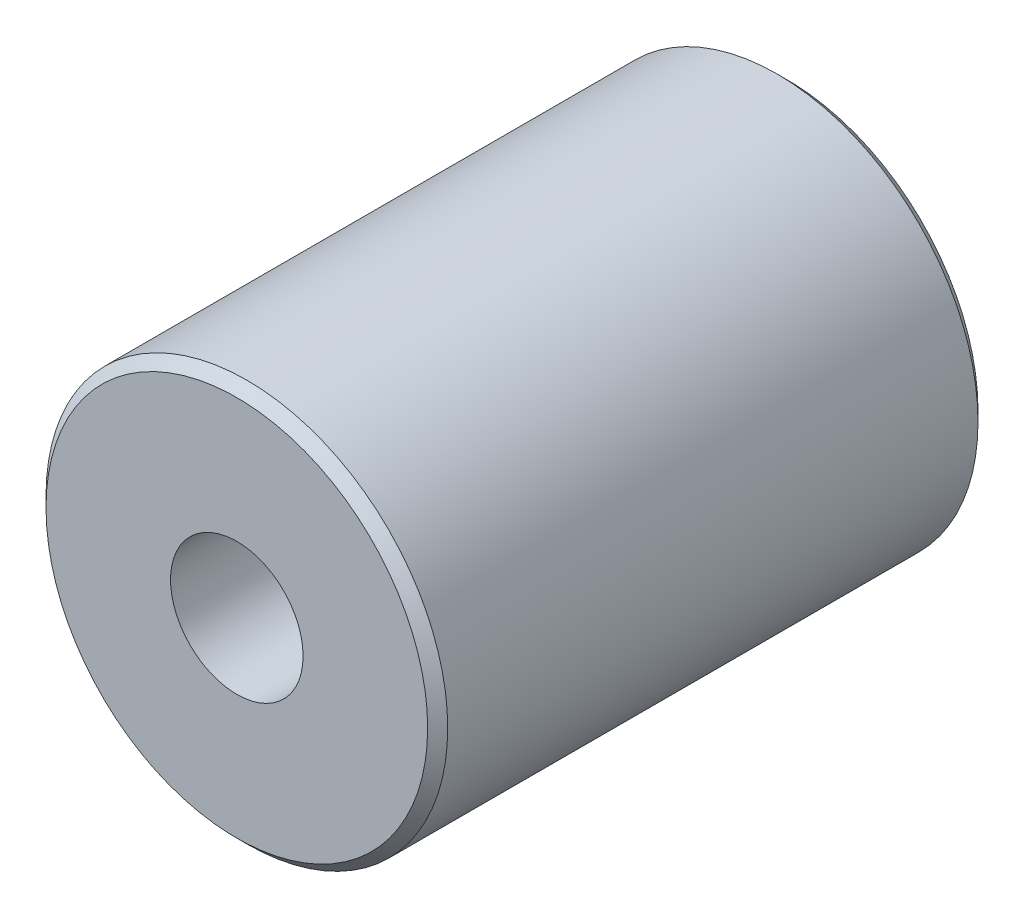
from build123d import *

# Parameters (mm, degrees)
SKETCH1_R                 = 5
EXTRUDE1_DEPTH            = 13.7
M4X0_7_TAPPED_HOLE1_D     = 3.3
M4X0_7_TAPPED_HOLE1_DEPTH = 10
M4X0_7_TAPPED_HOLE1_TIP   = 0.991420021
M4X0_7_TAPPED_HOLE2_D     = 3.3
M4X0_7_TAPPED_HOLE2_DEPTH = 10
M4X0_7_TAPPED_HOLE2_TIP   = 0.991420021
CHAMFER1_SIZE             = 0.25


with BuildPart() as part:
    # Sketch1 → Extrude1 (new body)
    with BuildSketch(Plane.XY):
        Circle(SKETCH1_R)
    extrude(amount=-EXTRUDE1_DEPTH)

    # M4x0.7 Tapped Hole1
    with Locations(Plane.XY):
        with Locations((0, 0)):
            Hole(M4X0_7_TAPPED_HOLE1_D / 2, depth=M4X0_7_TAPPED_HOLE1_DEPTH)
            with Locations((0, 0, -(M4X0_7_TAPPED_HOLE1_DEPTH + M4X0_7_TAPPED_HOLE1_TIP / 2))):  # 118° drill point
                Cone(0, M4X0_7_TAPPED_HOLE1_D / 2, M4X0_7_TAPPED_HOLE1_TIP, mode=Mode.SUBTRACT)

    # M4x0.7 Tapped Hole2
    with Locations(Plane(origin=(0, 0, -13.7), x_dir=(-1, 0, 0), z_dir=(0, 0, -1))):
        with Locations((0, 0)):
            Hole(M4X0_7_TAPPED_HOLE2_D / 2, depth=M4X0_7_TAPPED_HOLE2_DEPTH)
            with Locations((0, 0, -(M4X0_7_TAPPED_HOLE2_DEPTH + M4X0_7_TAPPED_HOLE2_TIP / 2))):  # 118° drill point
                Cone(0, M4X0_7_TAPPED_HOLE2_D / 2, M4X0_7_TAPPED_HOLE2_TIP, mode=Mode.SUBTRACT)

    # Chamfer1
    chamfer1_edges = [part.edges().sort_by_distance(p)[0] for p in [
        (-5, 0, 0),
        (-5, 0, -13.7),
    ]]
    chamfer(chamfer1_edges, length=CHAMFER1_SIZE)


solid = part.part
